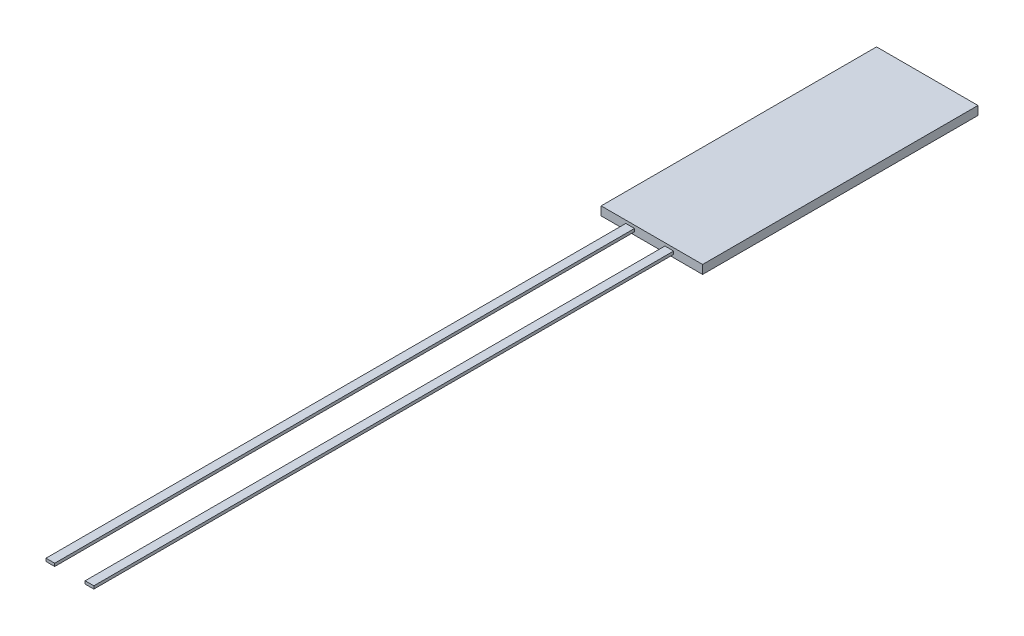
from build123d import *

# Parameters (mm, degrees)
SKETCH2_W           = 3.5
SKETCH2_H           = 9.5
BOSS_EXTRUDE1_DEPTH = 0.3
SKETCH3_W           = 0.3
SKETCH3_H           = 0.1
BOSS_EXTRUDE2_DEPTH = 20


with BuildPart() as part:
    # Sketch2 → Boss-Extrude1 (new body)
    with BuildSketch(Plane(origin=(0, 0, 0), x_dir=(1, 0, 0), z_dir=(0, 1, 0))):
        Rectangle(SKETCH2_W, SKETCH2_H)
    extrude(amount=BOSS_EXTRUDE1_DEPTH)

    # Sketch3 → Boss-Extrude2 (add)
    with BuildSketch(Plane.XY.offset(4.75)):
        with Locations((-0.75, 0.15)):
            Rectangle(SKETCH3_W, SKETCH3_H)
        with Locations((0.6, 0.15)):
            Rectangle(SKETCH3_W, SKETCH3_H)
    extrude(amount=BOSS_EXTRUDE2_DEPTH)


solid = part.part
